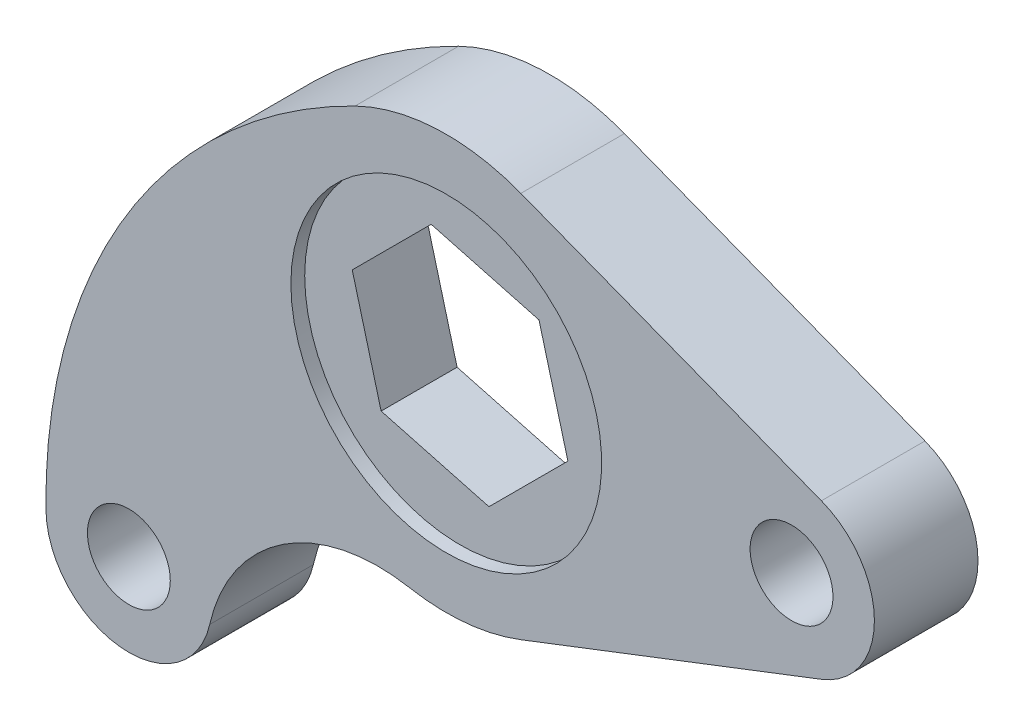
from build123d import *

# Parameters (mm, degrees)
SKETCH_1_R          = 6
EXTRUDE_2_DEPTH     = 7.5
CUT_EXTRUDE_START   = -7.5
SKETCH_4_R          = 22.5
CUT_EXTRUDE_4_DEPTH = 2
CUT_EXTRUDE_START_2 = 7.5
SKETCH_4_2_R        = 22.5
CUT_EXTRUDE_5_DEPTH = 2


with BuildPart() as part:
    # 草圖1 → 填料-伸長2 (new body, symmetric)
    with BuildSketch(Plane.XY):
        with BuildLine():
            Line((10.8, 27.988569095), (54.32, 11.195427638))
            ThreePointArc((54.32, 11.195427638), (62, 0), (54.32, -11.195427638))
            Line((54.32, -11.195427638), (10.8, -27.988569095))
            ThreePointArc((10.8, -27.988569095), (2.81349952, -29.867778968), (-5.383437031, -29.513024341))
            ThreePointArc((-5.383437031, -29.513024341), (-23.658051153, -33.253445018), (-34.256327949, -48.603650133))
            ThreePointArc((-34.256327949, -48.603650133), (-47.196522871, -57.898263789), (-57.960436879, -46.151917853))
            ThreePointArc((-57.960436879, -46.151917853), (-46.199430838, -3.114505899), (-13.217722281, 26.931242409))
            ThreePointArc((-13.217722281, 26.931242409), (-1.31940524, 29.97097212), (10.8, 27.988569095))
        make_face()
        with Locations((50, 0)):
            Circle(SKETCH_1_R, mode=Mode.SUBTRACT)
        with Locations((-45.961940777, -45.961940777)):
            Circle(SKETCH_1_R, mode=Mode.SUBTRACT)
        Polygon((15.614971003, -4.18401887), (11.430952133, 11.430952133), (-4.18401887, 15.614971003), (-15.614971003, 4.18401887), (-11.430952133, -11.430952133), (4.18401887, -15.614971003), align=None, mode=Mode.SUBTRACT)
    extrude(amount=EXTRUDE_2_DEPTH, both=True)

    # 草圖4 → 除料-伸長4 (cut)
    with BuildSketch(Plane.XY.offset(CUT_EXTRUDE_START)):
        Circle(SKETCH_4_R)
    extrude(amount=CUT_EXTRUDE_4_DEPTH, mode=Mode.SUBTRACT)

    # 草圖4<2> → 除料-伸長5 (cut)
    with BuildSketch(Plane.XY.offset(CUT_EXTRUDE_START_2)):
        Circle(SKETCH_4_2_R)
    extrude(amount=-CUT_EXTRUDE_5_DEPTH, mode=Mode.SUBTRACT)


solid = part.part
